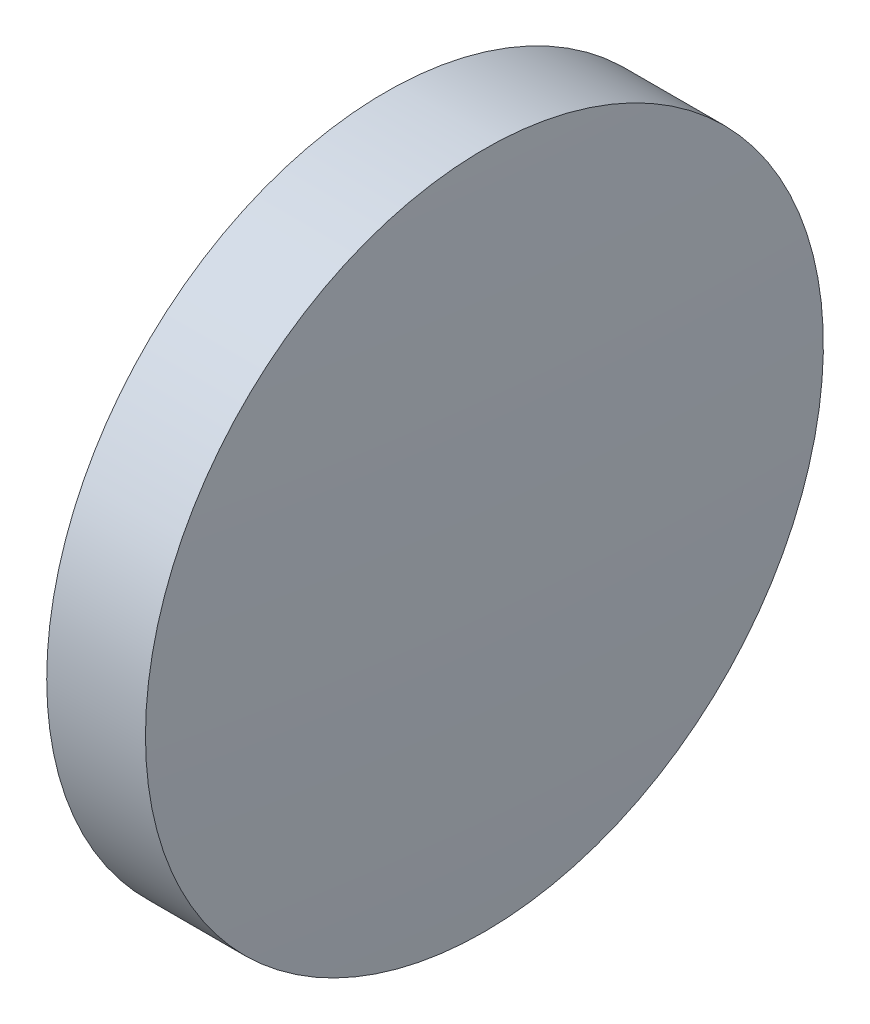
from build123d import *


with BuildPart() as part:
    # 草图1 → 旋转1 (revolve)
    with BuildSketch(Plane.XY, mode=Mode.PRIVATE) as revolve_1_sk:
        with BuildLine():
            Line((426.617851371, 74.763379419), (426.617851371, 87.463379419))
            Line((426.617851371, 87.463379419), (430.317851371, 87.463379419))
            ThreePointArc((430.317851371, 87.463379419), (430.542840912, 81.115150825), (430.617851371, 74.763379419))
            Line((430.617851371, 74.763379419), (426.617851371, 74.763379419))
        make_face()
    revolve(revolve_1_sk.sketch.rotate(Axis((420.879633336, 74.763379419, 0), (1, 0, 0)), 180), axis=Axis((420.879633336, 74.763379419, 0), (1, 0, 0)))  # turned: the seam where the file's is


solid = part.part
